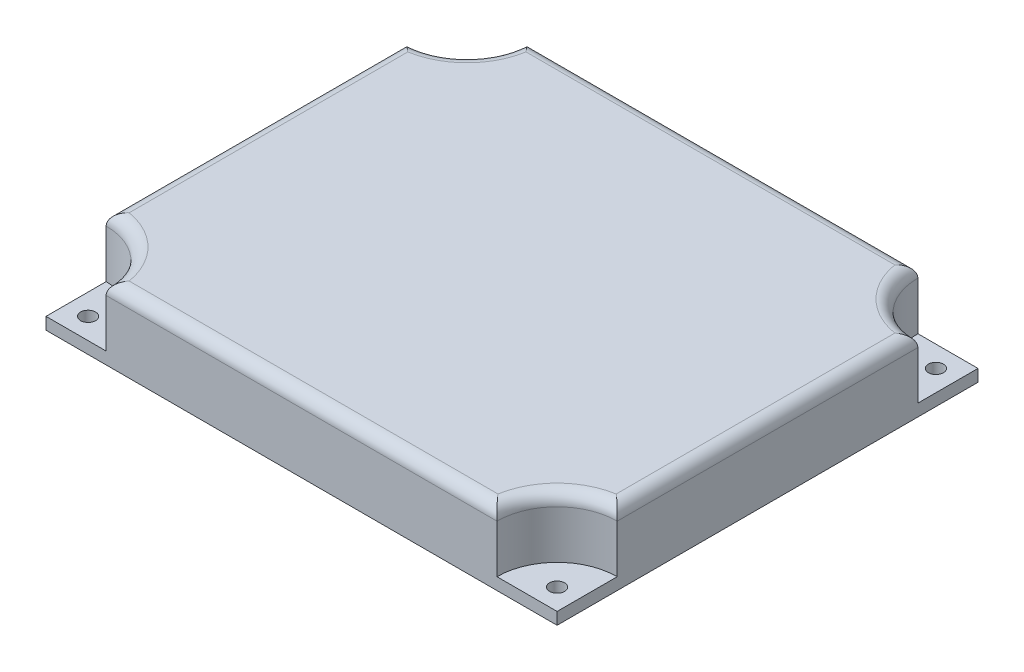
from build123d import *

# Parameters (mm, degrees)
SKETCH2_W                 = 85
SKETCH2_H                 = 70
BOSS_EXTRUDE1_DEPTH       = 12
SKETCH4_R                 = 10
CUT_EXTRUDE3_DEPTH        = 10
FILLET2_R                 = 2
M3X0_5_TAPPED_HOLE1_D     = 2.5
M3X0_5_TAPPED_HOLE1_DEPTH = 10
M3X0_5_TAPPED_HOLE1_TIP   = 0.751075774
CUT_EXTRUDE4_DEPTH        = 8


with BuildPart() as part:
    # Sketch2 → Boss-Extrude1 (new body)
    with BuildSketch(Plane(origin=(0, 0, 0), x_dir=(1, 0, 0), z_dir=(0, 1, 0))):
        Rectangle(SKETCH2_W, SKETCH2_H)
    extrude(amount=BOSS_EXTRUDE1_DEPTH)

    # Sketch4 → Cut-Extrude3 (cut)
    with BuildSketch(Plane(origin=(0, 12, 0), x_dir=(1, 0, 0), z_dir=(0, 1, 0))):
        with Locations((42.5, -35)):
            Circle(SKETCH4_R)
        with Locations((-42.5, -35)):
            Circle(SKETCH4_R)
        with Locations((-42.5, 35)):
            Circle(SKETCH4_R)
        with Locations((42.5, 35)):
            Circle(SKETCH4_R)
    extrude(amount=-CUT_EXTRUDE3_DEPTH, mode=Mode.SUBTRACT)

    # Fillet2
    fillet2_edges = [part.edges().sort_by_distance(p)[0] for p in [
        (42.5, 12, 0),
        (0, 12, -35),
        (-42.5, 12, 0),
        (0, 12, 35),
        (35.428932188, 12, -27.928932188),
        (-35.428932188, 12, -27.928932188),
        (-35.428932188, 12, 27.928932188),
        (35.428932188, 12, 27.928932188),
    ]]
    fillet(fillet2_edges, radius=FILLET2_R)

    # M3x0.5 Tapped Hole1
    with Locations(Plane(origin=(0, 2, 0), x_dir=(1, 0, 0), z_dir=(0, 1, 0))):
        with Locations((-39, 31.5), (-39, -31.5), (39, -31.5), (39, 31.5)):
            Hole(M3X0_5_TAPPED_HOLE1_D / 2, depth=M3X0_5_TAPPED_HOLE1_DEPTH)
            with Locations((0, 0, -(M3X0_5_TAPPED_HOLE1_DEPTH + M3X0_5_TAPPED_HOLE1_TIP / 2))):  # 118° drill point
                Cone(0, M3X0_5_TAPPED_HOLE1_D / 2, M3X0_5_TAPPED_HOLE1_TIP, mode=Mode.SUBTRACT)

    # Sketch8 → Cut-Extrude4 (cut)
    with BuildSketch(Plane.XZ):
        with BuildLine():
            Line((35.5, -25), (35.5, 25))
            ThreePointArc((35.5, 25), (34.914213562, 26.414213562), (33.5, 27))
            Line((33.5, 27), (-33.5, 27))
            ThreePointArc((-33.5, 27), (-34.914213562, 26.414213562), (-35.5, 25))
            Line((-35.5, 25), (-35.5, -25))
            ThreePointArc((-35.5, -25), (-34.914213562, -26.414213562), (-33.5, -27))
            Line((-33.5, -27), (33.5, -27))
            ThreePointArc((33.5, -27), (34.914213562, -26.414213562), (35.5, -25))
        make_face()
    extrude(amount=-CUT_EXTRUDE4_DEPTH, mode=Mode.SUBTRACT)


solid = part.part
